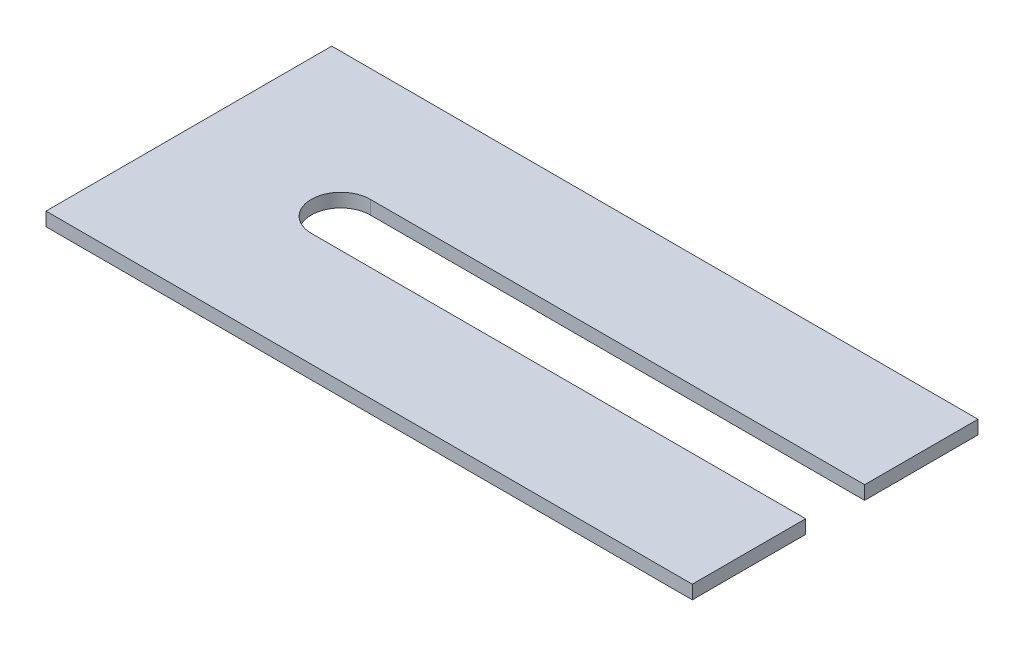
from build123d import *

# Parameters (mm, degrees)
BOSS_EXTRUDE1_DEPTH = 1.5


with BuildPart() as part:
    # Sketch1 → Boss-Extrude1 (new body)
    with BuildSketch(Plane(origin=(0, 0, 0), x_dir=(1, 0, 0), z_dir=(0, 1, 0))):
        with BuildLine():
            Line((0, 31.5), (0, 0))
            Line((0, 0), (71.25, 0))
            Line((71.25, 0), (71.25, 12.5))
            Line((71.25, 12.5), (16.75, 12.5))
            ThreePointArc((16.75, 12.5), (13.5, 15.75), (16.75, 19))
            Line((16.75, 19), (71.25, 19))
            Line((71.25, 19), (71.25, 31.5))
            Line((71.25, 31.5), (0, 31.5))
        make_face()
    extrude(amount=BOSS_EXTRUDE1_DEPTH)


solid = part.part
